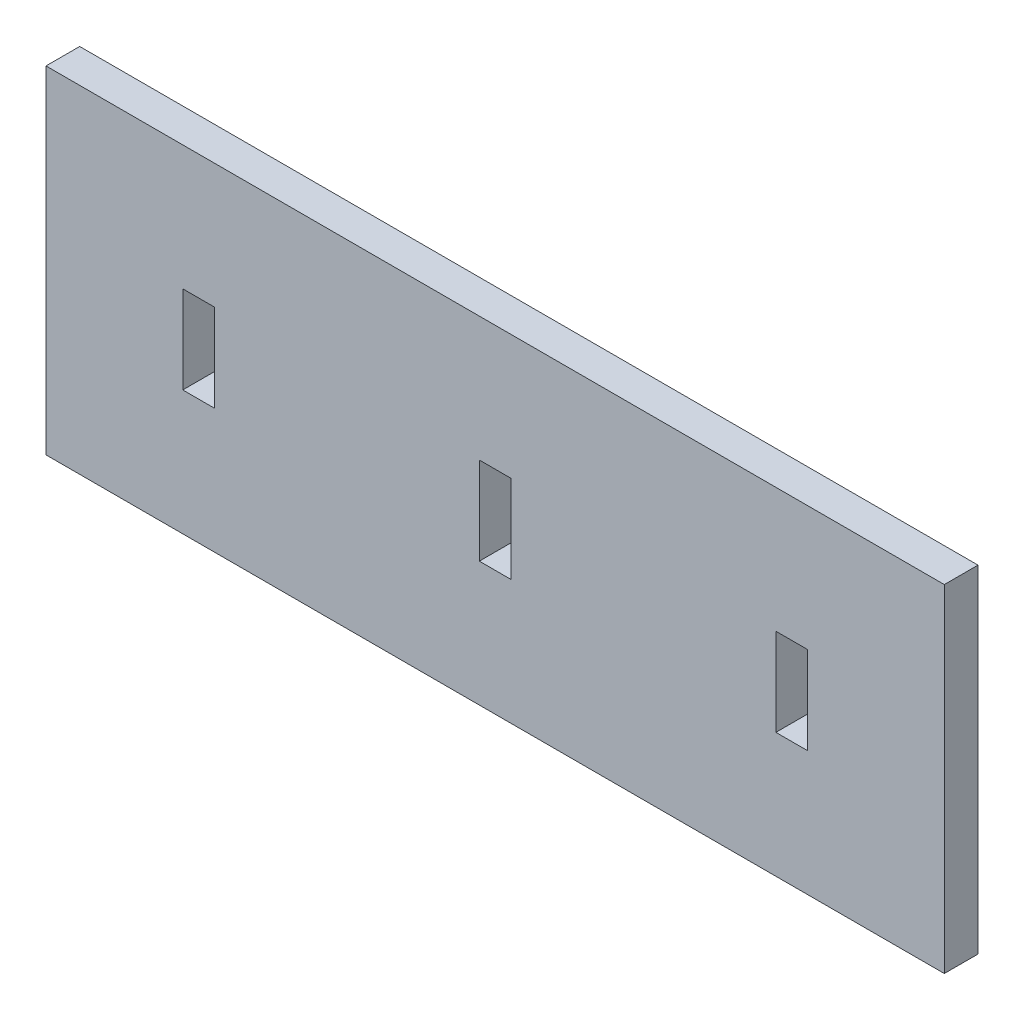
from build123d import *

# Parameters (mm, degrees)
SKETCH2_W           = 80
SKETCH2_H           = 30
SKETCH2_W_2         = 2.82
SKETCH2_H_2         = 7.8
BOSS_EXTRUDE1_DEPTH = 3


with BuildPart() as part:
    # Sketch2 → Boss-Extrude1 (new body)
    with BuildSketch(Plane.XY):
        Rectangle(SKETCH2_W, SKETCH2_H)
        with Locations((-26.41, 0)):
            Rectangle(SKETCH2_W_2, SKETCH2_H_2, mode=Mode.SUBTRACT)
        with Locations((26.41, 0)):
            Rectangle(SKETCH2_W_2, SKETCH2_H_2, mode=Mode.SUBTRACT)
        Rectangle(SKETCH2_W_2, SKETCH2_H_2, mode=Mode.SUBTRACT)
    extrude(amount=BOSS_EXTRUDE1_DEPTH)


solid = part.part
